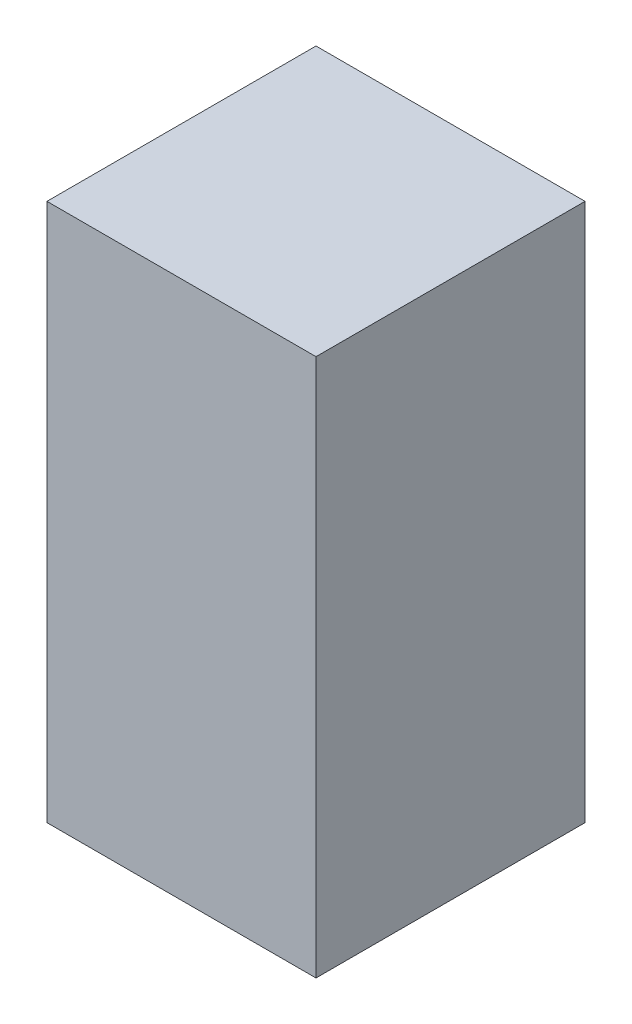
from build123d import *

# Parameters (mm, degrees)
SKETCH1_W           = 10
SKETCH1_H           = 10
BOSS_EXTRUDE1_DEPTH = 20


with BuildPart() as part:
    # Sketch1 → Boss-Extrude1 (new body)
    with BuildSketch(Plane(origin=(0, 0, 0), x_dir=(1, 0, 0), z_dir=(0, 1, 0))):
        with Locations((2.24137931, -1.666666667)):
            Rectangle(SKETCH1_W, SKETCH1_H)
    extrude(amount=BOSS_EXTRUDE1_DEPTH)


solid = part.part
